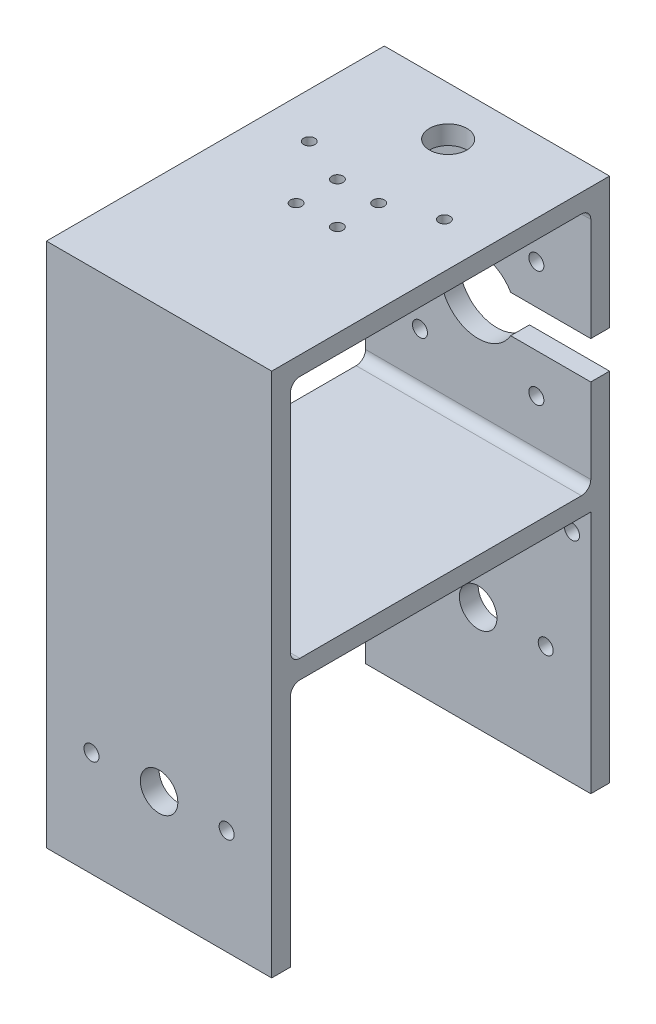
from build123d import *

# Parameters (mm, degrees)
BOSS_EXTRUDE1_DEPTH = 60
SKETCH2_W           = 80
SKETCH2_H           = 65
CUT_EXTRUDE1_DEPTH  = 60
CUT_EXTRUDE2_REACH  = 142
SKETCH3_R           = 1.5
SKETCH3_R_2         = 5
CUT_EXTRUDE3_REACH  = 92
SKETCH4_R           = 5
SKETCH4_R_2         = 10
SKETCH4_R_3         = 2
FILLET1_R           = 2.5
FILLET3_R           = 2.5
FILLET4_R           = 2.5
FILLET5_R           = 2.5
FILLET6_R           = 2.5
SKETCH5_R           = 5
SKETCH5_R_2         = 2
CUT_EXTRUDE4_DEPTH  = 91
CUT_EXTRUDE5_REACH  = 92
SKETCH6_W           = 30
SKETCH6_H           = 10


with BuildPart() as part:
    # Sketch1 → Boss-Extrude1 (new body)
    with BuildSketch(Plane(origin=(0, 0, 0), x_dir=(0, 0, -1), z_dir=(1, 0, 0))):
        Polygon((0, 0), (0, -140), (-5, -140), (-5, -75), (-85, -75), (-85, -140), (-90, -140), (-90, 0), align=None)
    extrude(amount=-BOSS_EXTRUDE1_DEPTH)

    # Sketch2 → Cut-Extrude1 (cut)
    with BuildSketch(Plane(origin=(0, 0, 0), x_dir=(0, 0, -1), z_dir=(1, 0, 0))):
        with Locations((-45, -37.5)):
            Rectangle(SKETCH2_W, SKETCH2_H)
    extrude(amount=-CUT_EXTRUDE1_DEPTH, mode=Mode.SUBTRACT)

    # Sketch3 → Cut-Extrude2 (cut, up to next)
    with BuildSketch(Plane(origin=(0, 0, 0), x_dir=(1, 0, 0), z_dir=(0, 1, 0)), mode=Mode.PRIVATE) as cut_extrude2_sk1:
        with Locations((-35.5, -37)):
            Circle(SKETCH3_R)
    cut_extrude2_tool1 = extrude(cut_extrude2_sk1.sketch, amount=-CUT_EXTRUDE2_REACH, mode=Mode.PRIVATE) & part.part
    add(cut_extrude2_tool1.solids().sort_by_distance((-35.5, 0, 37))[0], mode=Mode.SUBTRACT)
    # Sketch3 → Cut-Extrude2 (cut, up to next)
    with BuildSketch(Plane(origin=(0, 0, 0), x_dir=(1, 0, 0), z_dir=(0, 1, 0)), mode=Mode.PRIVATE) as cut_extrude2_sk2:
        with Locations((-24.5, -37)):
            Circle(SKETCH3_R)
    cut_extrude2_tool2 = extrude(cut_extrude2_sk2.sketch, amount=-CUT_EXTRUDE2_REACH, mode=Mode.PRIVATE) & part.part
    add(cut_extrude2_tool2.solids().sort_by_distance((-24.5, 0, 37))[0], mode=Mode.SUBTRACT)
    # Sketch3 → Cut-Extrude2 (cut, up to next)
    with BuildSketch(Plane(origin=(0, 0, 0), x_dir=(1, 0, 0), z_dir=(0, 1, 0)), mode=Mode.PRIVATE) as cut_extrude2_sk3:
        with Locations((-24.5, -48)):
            Circle(SKETCH3_R)
    cut_extrude2_tool3 = extrude(cut_extrude2_sk3.sketch, amount=-CUT_EXTRUDE2_REACH, mode=Mode.PRIVATE) & part.part
    add(cut_extrude2_tool3.solids().sort_by_distance((-24.5, 0, 48))[0], mode=Mode.SUBTRACT)
    # Sketch3 → Cut-Extrude2 (cut, up to next)
    with BuildSketch(Plane(origin=(0, 0, 0), x_dir=(1, 0, 0), z_dir=(0, 1, 0)), mode=Mode.PRIVATE) as cut_extrude2_sk4:
        with Locations((-35.5, -48)):
            Circle(SKETCH3_R)
    cut_extrude2_tool4 = extrude(cut_extrude2_sk4.sketch, amount=-CUT_EXTRUDE2_REACH, mode=Mode.PRIVATE) & part.part
    add(cut_extrude2_tool4.solids().sort_by_distance((-35.5, 0, 48))[0], mode=Mode.SUBTRACT)
    # Sketch3 → Cut-Extrude2 (cut, up to next)
    with BuildSketch(Plane(origin=(0, 0, 0), x_dir=(1, 0, 0), z_dir=(0, 1, 0)), mode=Mode.PRIVATE) as cut_extrude2_sk5:
        with Locations((-30, -13)):
            Circle(SKETCH3_R_2)
    cut_extrude2_tool5 = extrude(cut_extrude2_sk5.sketch, amount=-CUT_EXTRUDE2_REACH, mode=Mode.PRIVATE) & part.part
    add(cut_extrude2_tool5.solids().sort_by_distance((-30, 0, 13))[0], mode=Mode.SUBTRACT)
    # Sketch3 → Cut-Extrude2 (cut, up to next)
    with BuildSketch(Plane(origin=(0, 0, 0), x_dir=(1, 0, 0), z_dir=(0, 1, 0)), mode=Mode.PRIVATE) as cut_extrude2_sk6:
        with Locations((-12, -32)):
            Circle(SKETCH3_R)
    cut_extrude2_tool6 = extrude(cut_extrude2_sk6.sketch, amount=-CUT_EXTRUDE2_REACH, mode=Mode.PRIVATE) & part.part
    add(cut_extrude2_tool6.solids().sort_by_distance((-12, 0, 32))[0], mode=Mode.SUBTRACT)
    # Sketch3 → Cut-Extrude2 (cut, up to next)
    with BuildSketch(Plane(origin=(0, 0, 0), x_dir=(1, 0, 0), z_dir=(0, 1, 0)), mode=Mode.PRIVATE) as cut_extrude2_sk7:
        with Locations((-48, -32)):
            Circle(SKETCH3_R)
    cut_extrude2_tool7 = extrude(cut_extrude2_sk7.sketch, amount=-CUT_EXTRUDE2_REACH, mode=Mode.PRIVATE) & part.part
    add(cut_extrude2_tool7.solids().sort_by_distance((-48, 0, 32))[0], mode=Mode.SUBTRACT)

    # Sketch4 → Cut-Extrude3 (cut, up to next)
    with BuildSketch(Plane.XY, mode=Mode.PRIVATE) as cut_extrude3_sk1:
        with Locations((-30, -112)):
            Circle(SKETCH4_R)
    cut_extrude3_tool1 = extrude(cut_extrude3_sk1.sketch, amount=CUT_EXTRUDE3_REACH, mode=Mode.PRIVATE) & part.part
    add(cut_extrude3_tool1.solids().sort_by_distance((-30, -112, 0))[0], mode=Mode.SUBTRACT)
    # Sketch4 → Cut-Extrude3 (cut, up to next)
    with BuildSketch(Plane.XY, mode=Mode.PRIVATE) as cut_extrude3_sk2:
        with Locations((-30, -40)):
            Circle(SKETCH4_R_2)
    cut_extrude3_tool2 = extrude(cut_extrude3_sk2.sketch, amount=CUT_EXTRUDE3_REACH, mode=Mode.PRIVATE) & part.part
    add(cut_extrude3_tool2.solids().sort_by_distance((-30, -40, 0))[0], mode=Mode.SUBTRACT)
    # Sketch4 → Cut-Extrude3 (cut, up to next)
    with BuildSketch(Plane.XY, mode=Mode.PRIVATE) as cut_extrude3_sk3:
        with Locations((-5, -82)):
            Circle(SKETCH4_R_3)
    cut_extrude3_tool3 = extrude(cut_extrude3_sk3.sketch, amount=CUT_EXTRUDE3_REACH, mode=Mode.PRIVATE) & part.part
    add(cut_extrude3_tool3.solids().sort_by_distance((-5, -82, 0))[0], mode=Mode.SUBTRACT)
    # Sketch4 → Cut-Extrude3 (cut, up to next)
    with BuildSketch(Plane.XY, mode=Mode.PRIVATE) as cut_extrude3_sk4:
        with Locations((-55, -82)):
            Circle(SKETCH4_R_3)
    cut_extrude3_tool4 = extrude(cut_extrude3_sk4.sketch, amount=CUT_EXTRUDE3_REACH, mode=Mode.PRIVATE) & part.part
    add(cut_extrude3_tool4.solids().sort_by_distance((-55, -82, 0))[0], mode=Mode.SUBTRACT)
    # Sketch4 → Cut-Extrude3 (cut, up to next)
    with BuildSketch(Plane.XY, mode=Mode.PRIVATE) as cut_extrude3_sk5:
        with Locations((-14.5, -24.5)):
            Circle(SKETCH4_R_3)
    cut_extrude3_tool5 = extrude(cut_extrude3_sk5.sketch, amount=CUT_EXTRUDE3_REACH, mode=Mode.PRIVATE) & part.part
    add(cut_extrude3_tool5.solids().sort_by_distance((-14.5, -24.5, 0))[0], mode=Mode.SUBTRACT)
    # Sketch4 → Cut-Extrude3 (cut, up to next)
    with BuildSketch(Plane.XY, mode=Mode.PRIVATE) as cut_extrude3_sk6:
        with Locations((-45.5, -24.5)):
            Circle(SKETCH4_R_3)
    cut_extrude3_tool6 = extrude(cut_extrude3_sk6.sketch, amount=CUT_EXTRUDE3_REACH, mode=Mode.PRIVATE) & part.part
    add(cut_extrude3_tool6.solids().sort_by_distance((-45.5, -24.5, 0))[0], mode=Mode.SUBTRACT)
    # Sketch4 → Cut-Extrude3 (cut, up to next)
    with BuildSketch(Plane.XY, mode=Mode.PRIVATE) as cut_extrude3_sk7:
        with Locations((-45.5, -55.5)):
            Circle(SKETCH4_R_3)
    cut_extrude3_tool7 = extrude(cut_extrude3_sk7.sketch, amount=CUT_EXTRUDE3_REACH, mode=Mode.PRIVATE) & part.part
    add(cut_extrude3_tool7.solids().sort_by_distance((-45.5, -55.5, 0))[0], mode=Mode.SUBTRACT)
    # Sketch4 → Cut-Extrude3 (cut, up to next)
    with BuildSketch(Plane.XY, mode=Mode.PRIVATE) as cut_extrude3_sk8:
        with Locations((-14.5, -55.5)):
            Circle(SKETCH4_R_3)
    cut_extrude3_tool8 = extrude(cut_extrude3_sk8.sketch, amount=CUT_EXTRUDE3_REACH, mode=Mode.PRIVATE) & part.part
    add(cut_extrude3_tool8.solids().sort_by_distance((-14.5, -55.5, 0))[0], mode=Mode.SUBTRACT)

    # Fillet1
    fillet1_edges = [part.edges().sort_by_distance(p)[0] for p in [
        (-30, -75, 85),
    ]]
    fillet(fillet1_edges, radius=FILLET1_R)

    # Fillet3
    fillet3_edges = [part.edges().sort_by_distance(p)[0] for p in [
        (-30, -70, 85),
    ]]
    fillet(fillet3_edges, radius=FILLET3_R)

    # Fillet4
    fillet4_edges = [part.edges().sort_by_distance(p)[0] for p in [
        (-30, -70, 5),
    ]]
    fillet(fillet4_edges, radius=FILLET4_R)

    # Fillet5
    fillet5_edges = [part.edges().sort_by_distance(p)[0] for p in [
        (-30, -5, 5),
    ]]
    fillet(fillet5_edges, radius=FILLET5_R)

    # Fillet6
    fillet6_edges = [part.edges().sort_by_distance(p)[0] for p in [
        (-30, -5, 85),
    ]]
    fillet(fillet6_edges, radius=FILLET6_R)

    # Sketch5 → Cut-Extrude4 (cut, through all)
    with BuildSketch(Plane.XY.offset(90)):
        with Locations((-30, -112)):
            Circle(SKETCH5_R)
        with Locations((-12, -112)):
            Circle(SKETCH5_R_2)
        with Locations((-48, -112)):
            Circle(SKETCH5_R_2)
    extrude(amount=-CUT_EXTRUDE4_DEPTH, mode=Mode.SUBTRACT)

    # Sketch6 → Cut-Extrude5 (cut, up to next)
    with BuildSketch(Plane(origin=(0, 0, 0), x_dir=(-1, 0, 0), z_dir=(0, 0, -1)), mode=Mode.PRIVATE) as cut_extrude5_sk1:
        with Locations((15, -40)):
            Rectangle(SKETCH6_W, SKETCH6_H)
    cut_extrude5_tool1 = extrude(cut_extrude5_sk1.sketch, amount=-CUT_EXTRUDE5_REACH, mode=Mode.PRIVATE) & part.part
    add(cut_extrude5_tool1.solids().sort_by_distance((-15, -40, 0))[0], mode=Mode.SUBTRACT)


solid = part.part
